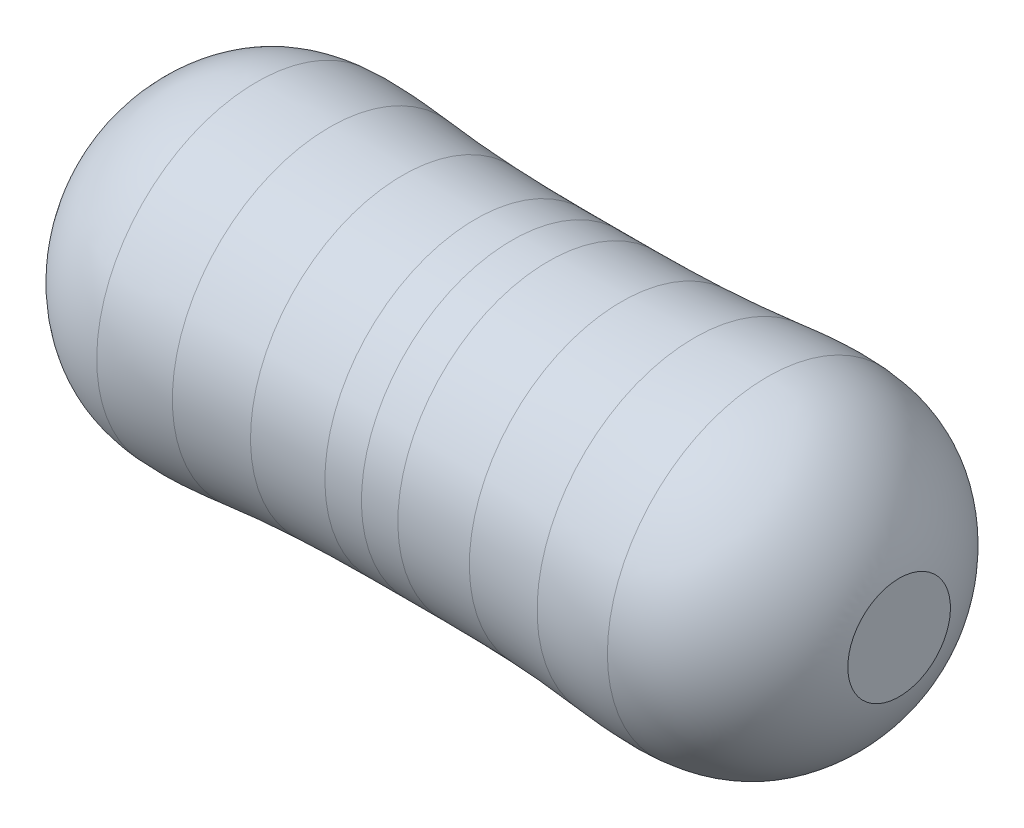
from build123d import *

# Parameters (mm, degrees)
SKETCH3_R          = 0.30479999999999996
SKETCH8_R          = 6.164171136290504
CUT_EXTRUDE1_DEPTH = 11.394859843298219
CUT_EXTRUDE2_START = 8.5
SKETCH8_2_R        = 6.164171136290504
CUT_EXTRUDE2_DEPTH = 2.894859843298219


with BuildPart() as part:
    # Base-Sweep: sweep along a path in Sketch1
    with BuildLine(Plane.XY) as base_sweep_path:
        Line((0, -2.54), (0, 1.016))
        ThreePointArc((0, 1.016), (0.22318463273585087, 1.5548153672641494), (0.762, 1.778))
    # Sketch3 → Base-Sweep (sweep)
    with BuildSketch(Plane(origin=(0, -2.54, 0), x_dir=(-1, 0, 0), z_dir=(0, 1, 0))):
        Circle(SKETCH3_R)
    sweep(path=base_sweep_path.line)

    # Sketch4 → Boss-Revolve1 (revolve)
    with BuildSketch(Plane.XY):
        with BuildLine():
            Line((5.054600000000001, 3.4290000000000003), (5.054600000000001, 1.778))
            Line((5.054600000000001, 1.778), (0.7619999999999998, 1.7779999999999996))
            add(Edge.make_bspline(
                [(0.7619999999999998, 1.7779999999999996), (0.7577984811626078, 1.8794424331425004), (0.7319399994614139, 2.503775538065161), (1.5817178580203402, 3.712321469151558), (3.3608825764965076, 3.428182395478029), (4.479173993062019, 3.428722225857275), (5.054600000000001, 3.4290000000000003)],
                knots=[0, 0, 0, 0, 0.05769047479405517, 0.3550592403677721, 0.668140450217807, 1, 1, 1, 1], degree=3))
        make_face()
    revolve(axis=Axis((0.7619999999999998, 1.7779999999999996, 0), (1, 1e-16, 0)))

    # Boss-Mirror1: part across plane


with BuildPart() as part_1:
    add(part.part)
    add(part.part.mirror(Plane(origin=(5.054600000000001, 3.4290000000000003, 0), x_dir=(0, 0, 1), z_dir=(1, 1e-16, 0))))

    # Sketch8 → Cut-Extrude1 (cut, through all)
    with BuildSketch(Plane(origin=(0.8, 0, 0), x_dir=(0, 0, -1), z_dir=(1, 0, 0))):
        Circle(SKETCH8_R)
    extrude(amount=-CUT_EXTRUDE1_DEPTH, mode=Mode.SUBTRACT)

    # Sketch8_2 → Cut-Extrude2 (cut, through all)
    with BuildSketch(Plane(origin=(0.8, 0, 0), x_dir=(0, 0, -1), z_dir=(1, 0, 0)).offset(CUT_EXTRUDE2_START)):
        Circle(SKETCH8_2_R)
    extrude(amount=CUT_EXTRUDE2_DEPTH, mode=Mode.SUBTRACT)


solid = part_1.part
